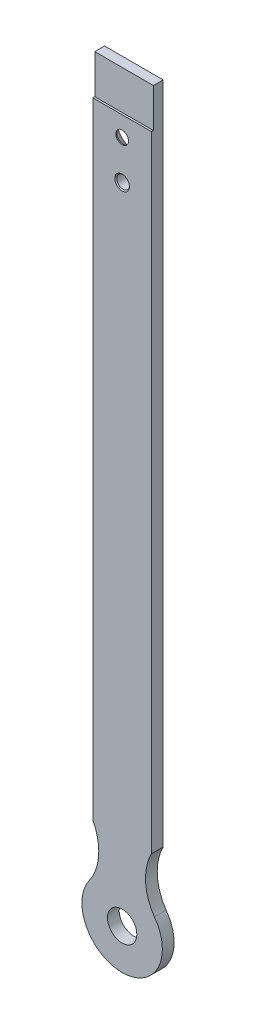
from build123d import *

# Parameters (mm, degrees)
SKETCH_1_R          = 3.25
SKETCH_1_R_2        = 7.5
EXTRUDE_1_DEPTH     = 6
SKETCH_2_W          = 1
SKETCH_2_H          = 19.943647813
CUT_EXTRUDE_1_DEPTH = 36.578503871
CHAMFER_1_SIZE      = 5.5
CHAMFER_2_SIZE      = 0.5


with BuildPart() as part:
    # Эскиз1 → Бобышка-Вытянуть1 (new body)
    with BuildSketch(Plane.XY):
        with BuildLine():
            Line((15, 60.126164395), (15, 400))
            Line((15, 400), (-15, 400))
            Line((-15, 400), (-15, 60.126164395))
            ThreePointArc((-15, 60.126164395), (-11.99467632, 46.284317121), (-16.512069377, 32.859643332))
            ThreePointArc((-16.512069377, 32.859643332), (0, 0), (16.512069377, 32.859643332))
            ThreePointArc((16.512069377, 32.859643332), (11.99467632, 46.284317121), (15, 60.126164395))
        make_face()
        with Locations((0, 370)):
            Circle(SKETCH_1_R, mode=Mode.SUBTRACT)
        with Locations((0, 350)):
            Circle(SKETCH_1_R, mode=Mode.SUBTRACT)
        with Locations((0, 20.578503871)):
            Circle(SKETCH_1_R_2, mode=Mode.SUBTRACT)
    extrude(amount=EXTRUDE_1_DEPTH)

    # Эскиз2 → Вырез-Вытянуть1 (cut, through all)
    with BuildSketch(Plane.ZY.offset(15)):
        with Locations((5.5, 390.028176094)):
            Rectangle(SKETCH_2_W, SKETCH_2_H)
    extrude(amount=-CUT_EXTRUDE_1_DEPTH, mode=Mode.SUBTRACT)

    # Фаска1
    chamfer_1_edges = [part.edges().sort_by_distance(p)[0] for p in [
        (-3.25, 370, 0),
    ]]
    chamfer(chamfer_1_edges, length=CHAMFER_1_SIZE)

    # Фаска2
    chamfer_2_edges = [part.edges().sort_by_distance(p)[0] for p in [
        (-3.25, 350, 0),
        (-3.25, 350, 6),
    ]]
    chamfer(chamfer_2_edges, length=CHAMFER_2_SIZE)


solid = part.part
